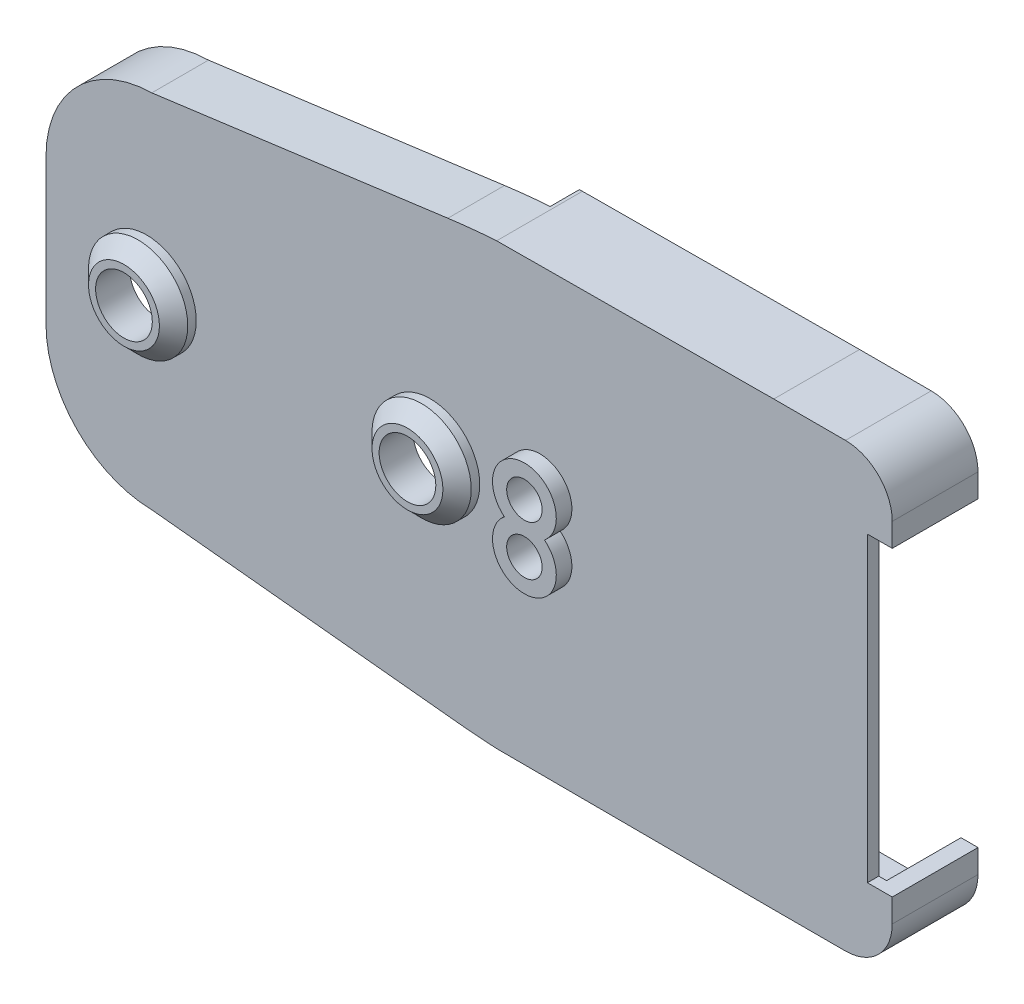
from build123d import *

# Parameters (mm, degrees)
SKETCH1_R           = 2
SKETCH1_R_2         = 1.25
BOSS_EXTRUDE1_DEPTH = 0.8
BOSS_EXTRUDE2_DEPTH = 1.7
BOSS_EXTRUDE5_START = -5.25
BOSS_EXTRUDE5_DEPTH = 5.25
CUT_EXTRUDE1_DEPTH  = 2.05
CUT_EXTRUDE2_DEPTH  = 5.25
SKETCH4_R           = 3.5
SKETCH4_R_2         = 2
SKETCH4_R_3         = 2.25
SKETCH4_R_4         = 1.25
BOSS_EXTRUDE6_DEPTH = 1.6
CHAMFER1_SIZE       = 1
CUT_EXTRUDE3_START  = -0.5
CUT_EXTRUDE3_DEPTH  = 0.5


with BuildPart() as part:
    # Sketch1 → Boss-Extrude1 (new body)
    with BuildSketch(Plane.XY):
        with BuildLine():
            Line((47.747323671, -3.6), (52.8, -3.6))
            ThreePointArc((52.8, -3.6), (55.133452378, -2.633452378), (56.1, -0.3))
            Line((56.1, -0.3), (56.1, 1.35))
            Line((56.1, 1.35), (54.35, 1.35))
            Line((54.35, 1.35), (54.35, 22.65))
            Line((54.35, 22.65), (56.1, 22.65))
            Line((56.1, 22.65), (56.1, 24.3))
            ThreePointArc((56.1, 24.3), (55.133452378, 26.633452378), (52.8, 27.6))
            Line((52.8, 27.6), (47.745478955, 27.6))
            Line((47.745478955, 27.6), (28.192723723, 27.48950052))
            ThreePointArc((28.192723723, 27.48950052), (26.4684207, 27.34740533), (24.749850743, 27.147582262))
            Line((24.749850743, 27.147582262), (3.864159561, 24.363517328))
            ThreePointArc((3.864159561, 24.363517328), (-1.421825677, 22.090499558), (-3.6, 16.764731413))
            Line((-3.6, 16.764731413), (-3.6, 6.485268587))
            ThreePointArc((-3.6, 6.485268587), (-1.412746343, 1.150273083), (3.890046585, -1.113935993))
            Line((3.890046585, -1.113935993), (25.547001239, -3.33158265))
            ThreePointArc((25.547001239, -3.33158265), (26.875561897, -3.450295565), (28.206747131, -3.534628551))
            Line((28.206747131, -3.534628551), (47.747323671, -3.6))
        make_face()
        with Locations((3.5, 12)):
            Circle(SKETCH1_R, mode=Mode.SUBTRACT)
        with Locations((23.5, 12)):
            Circle(SKETCH1_R, mode=Mode.SUBTRACT)
        with Locations((31.25, 13.75)):
            Circle(SKETCH1_R_2, mode=Mode.SUBTRACT)
        with Locations((31.25, 10.25)):
            Circle(SKETCH1_R_2, mode=Mode.SUBTRACT)
    extrude(amount=BOSS_EXTRUDE1_DEPTH)

    # Sketch1_3 → Boss-Extrude2 (add)
    with BuildSketch(Plane.XY):
        with BuildLine():
            Line((27.968417848, -1.919570033), (27.968417848, 25.870274099))
            ThreePointArc((27.968417848, 25.870274099), (27.217924724, 25.810423929), (26.468417848, 25.739280302))
            Line((26.468417848, 25.739280302), (26.468417848, -1.811733972))
            ThreePointArc((26.468417848, -1.811733972), (27.218012396, -1.871291838), (27.968417848, -1.919570033))
        make_face()
        with BuildLine():
            Line((27.968417848, -2.320209383), (27.968417848, -1.919570033))
            ThreePointArc((27.968417848, -1.919570033), (27.218012396, -1.871291838), (26.468417848, -1.811733972))
            Line((26.468417848, -1.811733972), (26.468417848, -2.213233726))
            ThreePointArc((26.468417848, -2.213233726), (27.21801884, -2.272316396), (27.968417848, -2.320209383))
        make_face()
        with BuildLine():
            ThreePointArc((26.468417848, 25.739280302), (27.217924724, 25.810423929), (27.968417848, 25.870274099))
            Line((27.968417848, 25.870274099), (27.968417848, 26.271306316))
            ThreePointArc((27.968417848, 26.271306316), (27.21793258, 26.21193484), (26.468417848, 26.141360223))
            Line((26.468417848, 26.141360223), (26.468417848, 25.739280302))
        make_face()
    extrude(amount=-BOSS_EXTRUDE2_DEPTH)

    # Sketch1_4 → Boss-Extrude5 (add)
    with BuildSketch(Plane.XY.offset(BOSS_EXTRUDE5_START)):
        with BuildLine():
            Line((28.206747131, -3.534628551), (47.747323671, -3.6))
            Line((47.747323671, -3.6), (52.8, -3.6))
            ThreePointArc((52.8, -3.6), (55.133452378, -2.633452378), (56.1, -0.3))
            Line((56.1, -0.3), (56.1, 1.35))
            Line((56.1, 1.35), (54.35, 1.35))
            Line((54.35, 1.35), (54.35, 22.65))
            Line((54.35, 22.65), (56.1, 22.65))
            Line((56.1, 22.65), (56.1, 24.3))
            ThreePointArc((56.1, 24.3), (55.133452378, 26.633452378), (52.8, 27.6))
            Line((52.8, 27.6), (47.745478955, 27.6))
            Line((47.745478955, 27.6), (28.192723723, 27.48950052))
            ThreePointArc((28.192723723, 27.48950052), (26.4684207, 27.34740533), (24.749850743, 27.147582262))
            Line((24.749850743, 27.147582262), (3.864159561, 24.363517328))
            ThreePointArc((3.864159561, 24.363517328), (-1.421825677, 22.090499558), (-3.6, 16.764731413))
            Line((-3.6, 16.764731413), (-3.6, 6.485268587))
            ThreePointArc((-3.6, 6.485268587), (-1.412746343, 1.150273083), (3.890046585, -1.113935993))
            Line((3.890046585, -1.113935993), (25.547001239, -3.33158265))
            ThreePointArc((25.547001239, -3.33158265), (26.875561897, -3.450295565), (28.206747131, -3.534628551))
        make_face()
        with BuildLine():
            Line((28.235609368, 26.289723719), (47.748869739, 26.4))
            Line((47.748869739, 26.4), (52.8, 26.4))
            ThreePointArc((52.8, 26.4), (54.28492424, 25.78492424), (54.9, 24.3))
            Line((54.9, 24.3), (54.9, 23.85))
            Line((54.9, 23.85), (53.15, 23.85))
            Line((53.15, 23.85), (53.15, 0.15))
            Line((53.15, 0.15), (54.9, 0.15))
            Line((54.9, 0.15), (54.9, -0.3))
            ThreePointArc((54.9, -0.3), (54.28492424, -1.78492424), (52.8, -2.4))
            Line((52.8, -2.4), (47.749330923, -2.4))
            Line((47.749330923, -2.4), (28.239130572, -2.334730172))
            ThreePointArc((28.239130572, -2.334730172), (26.952926693, -2.252708036), (25.669240626, -2.137824914))
            Line((25.669240626, -2.137824914), (3.957730332, 0.085408176))
            ThreePointArc((3.957730332, 0.085408176), (-0.540403389, 1.974754529), (-2.4, 6.485268587))
            Line((-2.4, 6.485268587), (-2.4, 16.764731413))
            ThreePointArc((-2.4, 16.764731413), (-0.542592126, 21.273041161), (3.951517744, 23.164547776))
            Line((3.951517744, 23.164547776), (24.908408379, 25.958103605))
            ThreePointArc((24.908408379, 25.958103605), (26.569258033, 26.151513311), (28.235609368, 26.289723719))
        make_face(mode=Mode.SUBTRACT)
    extrude(amount=BOSS_EXTRUDE5_DEPTH)

    # Sketch2 → Cut-Extrude1 (cut)
    with BuildSketch(Plane(origin=(0, 0, -5.25), x_dir=(-1, 0, 0), z_dir=(0, 0, -1))):
        with BuildLine():
            Line((-27.968417848, 27.474306588), (-27.968417848, 26.271306316))
            ThreePointArc((-27.968417848, 26.271306316), (-26.436023146, 26.138055085), (-24.908408379, 25.958103605))
            Line((-24.908408379, 25.958103605), (-3.951517744, 23.164547776))
            ThreePointArc((-3.951517744, 23.164547776), (0.542592126, 21.273041161), (2.4, 16.764731413))
            Line((2.4, 16.764731413), (2.4, 6.485268587))
            ThreePointArc((2.4, 6.485268587), (0.540403389, 1.974754529), (-3.957730332, 0.085408176))
            Line((-3.957730332, 0.085408176), (-25.669240626, -2.137824914))
            ThreePointArc((-25.669240626, -2.137824914), (-26.817785818, -2.24217071), (-27.968417848, -2.320209383))
            Line((-27.968417848, -2.320209383), (-27.968417848, -3.522067819))
            ThreePointArc((-27.968417848, -3.522067819), (-26.756588582, -3.441074719), (-25.547001239, -3.33158265))
            Line((-25.547001239, -3.33158265), (-3.890046585, -1.113935993))
            ThreePointArc((-3.890046585, -1.113935993), (1.412746343, 1.150273083), (3.6, 6.485268587))
            Line((3.6, 6.485268587), (3.6, 16.764731413))
            ThreePointArc((3.6, 16.764731413), (1.421825677, 22.090499558), (-3.864159561, 24.363517328))
            Line((-3.864159561, 24.363517328), (-24.749850743, 27.147582262))
            ThreePointArc((-24.749850743, 27.147582262), (-26.356573132, 27.336174491), (-27.968417848, 27.474306588))
        make_face()
        with BuildLine():
            ThreePointArc((-24.908408379, 25.958103605), (-26.436023146, 26.138055085), (-27.968417848, 26.271306316))
            Line((-27.968417848, 26.271306316), (-27.968417848, -2.320209383))
            ThreePointArc((-27.968417848, -2.320209383), (-26.817785818, -2.24217071), (-25.669240626, -2.137824914))
            Line((-25.669240626, -2.137824914), (-3.957730332, 0.085408176))
            ThreePointArc((-3.957730332, 0.085408176), (0.540403389, 1.974754529), (2.4, 6.485268587))
            Line((2.4, 6.485268587), (2.4, 16.764731413))
            ThreePointArc((2.4, 16.764731413), (0.542592126, 21.273041161), (-3.951517744, 23.164547776))
            Line((-3.951517744, 23.164547776), (-24.908408379, 25.958103605))
        make_face()
    extrude(amount=-CUT_EXTRUDE1_DEPTH, mode=Mode.SUBTRACT)

    # Sketch3 → Cut-Extrude2 (cut)
    with BuildSketch(Plane(origin=(0, 0, -5.25), x_dir=(-1, 0, 0), z_dir=(0, 0, -1))):
        Polygon((-53.15, 23.85), (-54.9, 23.85), (-54.9, 22.65), (-54.35, 22.65), (-54.35, 1.35), (-54.9, 1.35), (-54.9, 0.15), (-53.15, 0.15), align=None)
    extrude(amount=-CUT_EXTRUDE2_DEPTH, mode=Mode.SUBTRACT)

    # Sketch4 → Boss-Extrude6 (add)
    # profile 1 of 4: a face of its own
    with BuildSketch(Plane.XY.offset(0.8)):
        with Locations((3.5, 12)):
            Circle(SKETCH4_R)
        with Locations((3.5, 12)):
            Circle(SKETCH4_R_2, mode=Mode.SUBTRACT)
    # profile 2 of 4: a face of its own
    with BuildSketch(Plane.XY.offset(0.8)):
        with Locations((23.5, 12)):
            Circle(SKETCH4_R)
        with Locations((23.5, 12)):
            Circle(SKETCH4_R_2, mode=Mode.SUBTRACT)
    # profile 3 of 4: a face of its own
    with BuildSketch(Plane.XY.offset(0.8)):
        with Locations((31.25, 13.75)):
            Circle(SKETCH4_R_3)
        with Locations((31.25, 13.75)):
            Circle(SKETCH4_R_4, mode=Mode.SUBTRACT)
    # profile 4 of 4: a face of its own
    with BuildSketch(Plane.XY.offset(0.8)):
        with Locations((31.25, 10.25)):
            Circle(SKETCH4_R_3)
        with Locations((31.25, 10.25)):
            Circle(SKETCH4_R_4, mode=Mode.SUBTRACT)
    extrude(amount=BOSS_EXTRUDE6_DEPTH)

    # Chamfer1
    chamfer1_edges = [part.edges().sort_by_distance(p)[0] for p in [
        (0, 12, 2.4),
        (20, 12, 2.4),
    ]]
    chamfer(chamfer1_edges, length=CHAMFER1_SIZE)

    # Sketch5 → Cut-Extrude3 (cut)
    with BuildSketch(Plane.XY.offset(2.4).offset(CUT_EXTRUDE3_START)):
        with BuildLine():
            ThreePointArc((32.664213562, 12), (31.25, 16), (29.835786438, 12))
            ThreePointArc((29.835786438, 12), (31.25, 8), (32.664213562, 12))
        make_face()
    extrude(amount=CUT_EXTRUDE3_DEPTH, mode=Mode.SUBTRACT)


solid = part.part
